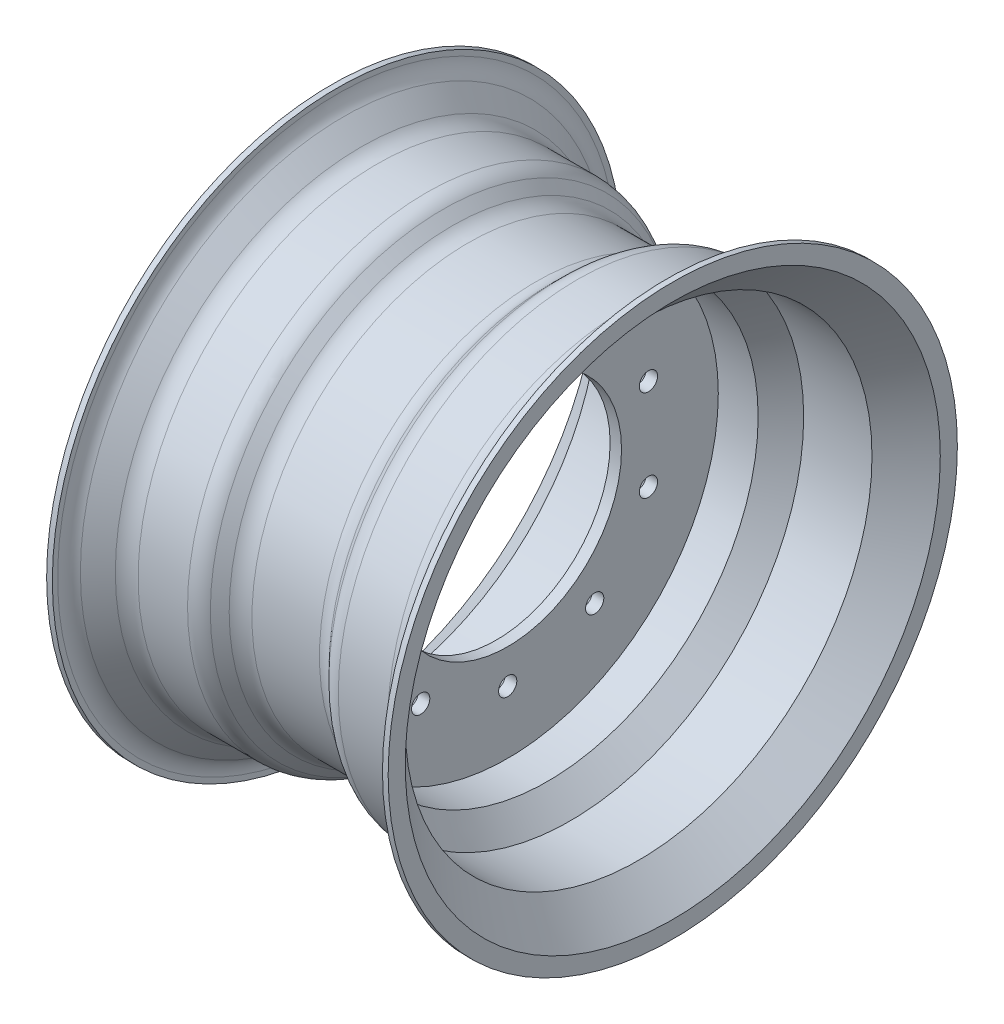
from build123d import *

# Parameters (mm, degrees)
FILLET1_R          = 20
SKETCH5_R          = 8
CUT_EXTRUDE1_DEPTH = 156
CIRPATTERN1_COUNT  = 10


with BuildPart() as part:
    # Sketch4 → Revolve1 (revolve)
    with BuildSketch(Plane.XY):
        Polygon((-150, 250), (-150, 235), (-120, 205), (-60, 205), (-40, 185), (-5, 185), (-5, 100), (5, 100), (5, 185), (40, 185), (60, 205), (120, 205), (150, 235), (150, 250), (145, 250), (145, 237.071067812), (117.928932188, 210), (57.928932188, 210), (37.928932188, 190), (-37.928932188, 190), (-57.928932188, 210), (-117.928932188, 210), (-145, 237.071067812), (-145, 250), align=None)
    revolve(axis=Axis((0, 0, 0), (-1, 0, 0)))

    # Fillet1
    fillet1_edges = [part.edges().sort_by_distance(p)[0] for p in [
        (145, -237.071067812, 0),
        (117.928932188, -210, 0),
        (57.928932188, -210, 0),
        (37.928932188, -190, 0),
        (-37.928932188, -190, 0),
        (-57.928932188, -210, 0),
        (-117.928932188, -210, 0),
        (-145, -237.071067812, 0),
    ]]
    fillet(fillet1_edges, radius=FILLET1_R)

    # Sketch5 → Cut-Extrude1 (cut, through all)
    with BuildSketch(Plane(origin=(5, 0, 0), x_dir=(0, 0, -1), z_dir=(1, 0, 0))):
        with Locations((0, 130)):
            Circle(SKETCH5_R)
    cut_extrude1 = extrude(amount=-CUT_EXTRUDE1_DEPTH, mode=Mode.SUBTRACT)

    # CirPattern1: Cut-Extrude1 ×10 about axis
    cirpattern1_axis = Axis((0, 0, 0), (1, 0, 0))
    for i in range(1, CIRPATTERN1_COUNT):
        add(cut_extrude1.rotate(cirpattern1_axis, i * 360 / CIRPATTERN1_COUNT), mode=Mode.SUBTRACT)


solid = part.part
